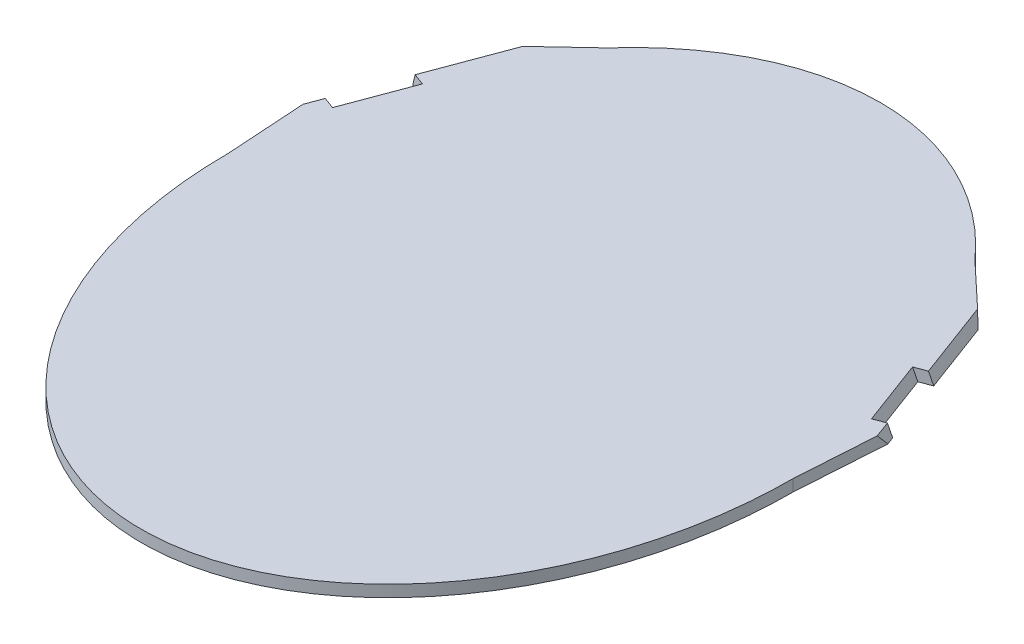
from build123d import *

# Parameters (mm, degrees)
SKETCH1_RX          = 380
SKETCH1_RY          = 290
BOSS_EXTRUDE1_DEPTH = 12
BOSS_EXTRUDE2_DEPTH = 12
CUT_EXTRUDE1_DEPTH  = 12
SKETCH8_W           = 355.795250099
SKETCH8_H           = 262.515596516
CUT_EXTRUDE2_DEPTH  = 100.064634015


with BuildPart() as part:
    # Sketch1 → Boss-Extrude1 (new body)
    with BuildSketch(Plane(origin=(0, 0, 0), x_dir=(1, 0, 0), z_dir=(0, 1, 0))):
        with Locations(Location((0, 0), (0, 0, 90))):
            Ellipse(SKETCH1_RX, SKETCH1_RY)
    extrude(amount=BOSS_EXTRUDE1_DEPTH)

    # Sketch2 → Boss-Extrude2 (add)
    with BuildSketch(Plane(origin=(0, 12, 0), x_dir=(1, 0, 0), z_dir=(0, 1, 0))):
        with BuildLine():
            Line((-267.843332661, 167.00986407), (-255.933258601, 162.566200507))
            Line((-255.933258601, 162.566200507), (-281.041243921, 95.270834767))
            Line((-281.041243921, 95.270834767), (-292.951317982, 99.714498329))
            Line((-292.951317982, 99.714498329), (-295.908396975, 91.788824093))
            Line((-295.908396975, 91.788824093), (-290, 0))
            add(Edge.make_bspline(
                [(-290, 0), (-290, -380), (0, -380), (290, -380), (290, 0)],
                knots=[1.570796327, 1.570796327, 1.570796327, 3.141592654, 3.141592654, 4.71238898, 4.71238898, 4.71238898], degree=2, weights=[1, 0.707106781, 1, 0.707106781, 1]))
            Line((290, 0), (295.908396975, 91.788824093))
            Line((295.908396975, 91.788824093), (292.951317982, 99.714498329))
            Line((292.951317982, 99.714498329), (281.041243921, 95.270834767))
            Line((281.041243921, 95.270834767), (255.933258601, 162.566200507))
            Line((255.933258601, 162.566200507), (267.843332661, 167.00986407))
            Line((267.843332661, 167.00986407), (240.741863408, 239.648240356))
            Line((240.741863408, 239.648240356), (188.989530622, 288.225103524))
            add(Edge.make_bspline(
                [(188.989530622, 288.225103524), (0, 500.997304657), (-188.989530622, 288.225103524)],
                knots=[5.573377461, 5.573377461, 5.573377461, 6.992993153, 6.992993153, 6.992993153], degree=2, weights=[1, 0.758487115, 1]))
            Line((-188.989530622, 288.225103524), (-240.741863408, 239.648240356))
            Line((-240.741863408, 239.648240356), (-267.843332661, 167.00986407))
        make_face()
    extrude(amount=-BOSS_EXTRUDE2_DEPTH)

    # Sketch4 → Cut-Extrude1 (cut)
    with BuildSketch(Plane(origin=(258.254517009, 96.35508405, -96.35508405), x_dir=(-0.309165432, -0.11535001, -0.943986817), z_dir=(0.884433277, 0.329983165, -0.329983165))):
        Polygon((1.492832846, -85.624929823), (-0.145048347, -72.321491364), (71.14341089, -63.544660692), (72.781292083, -76.84809915), (74.847210502, -93.628204232), (3.558751265, -102.405034904), align=None)
    cut_extrude1 = extrude(amount=-CUT_EXTRUDE1_DEPTH, mode=Mode.SUBTRACT)

    # Mirror1: Cut-Extrude1 across plane
    add(cut_extrude1.mirror(Plane(origin=(0, 0, 0), x_dir=(0, 0, 1), z_dir=(1, 0, 0))), mode=Mode.SUBTRACT)

    # Sketch8 → Cut-Extrude2 (cut, through all)
    with BuildSketch(Plane(origin=(258.254517009, 96.35508405, -96.35508405), x_dir=(-0.309165432, -0.11535001, -0.943986817), z_dir=(0.884433277, 0.329983165, -0.329983165))):
        with Locations((60.595009972, -108.189381189)):
            Rectangle(SKETCH8_W, SKETCH8_H)
    cut_extrude2 = extrude(amount=CUT_EXTRUDE2_DEPTH, mode=Mode.SUBTRACT)

    # Mirror2: Cut-Extrude2 across plane
    add(cut_extrude2.mirror(Plane(origin=(0, 0, 0), x_dir=(0, 0, 1), z_dir=(1, 0, 0))), mode=Mode.SUBTRACT)


solid = part.part
